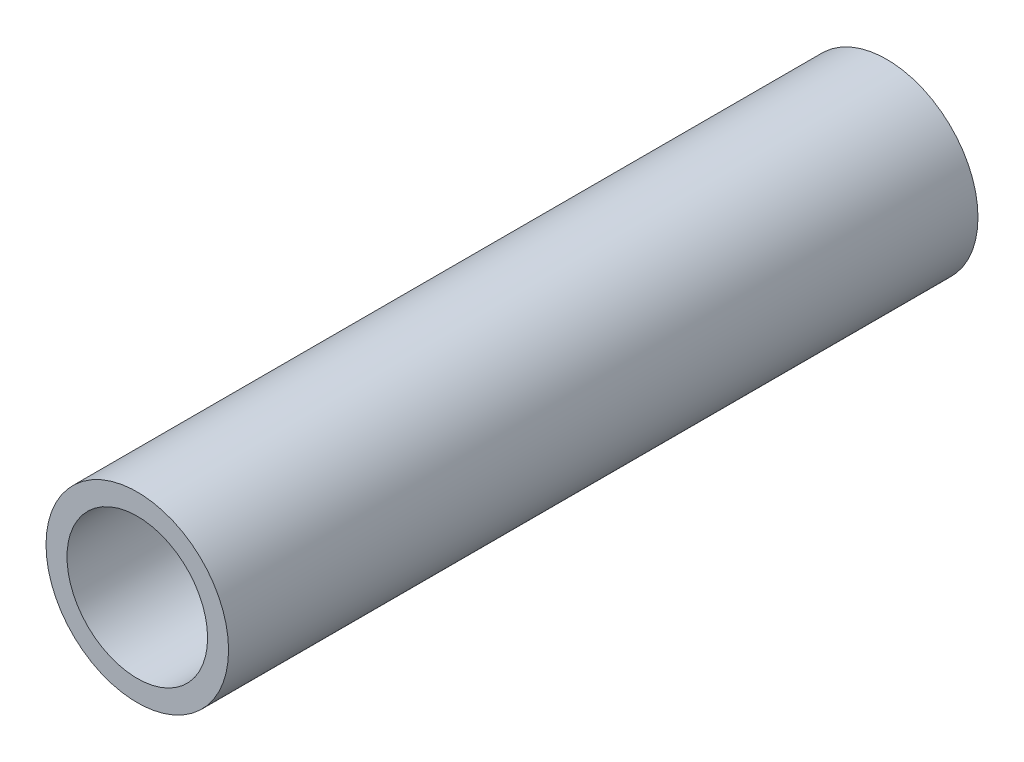
from build123d import *

# Parameters (mm, degrees)
SKETCH1_R           = 30.4515
SKETCH1_R_2         = 23.4515
BOSS_EXTRUDE1_DEPTH = 250


with BuildPart() as part:
    # Sketch1 → Boss-Extrude1 (new body)
    with BuildSketch(Plane.XY):
        Circle(SKETCH1_R)
        Circle(SKETCH1_R_2, mode=Mode.SUBTRACT)
    extrude(amount=BOSS_EXTRUDE1_DEPTH)


solid = part.part
